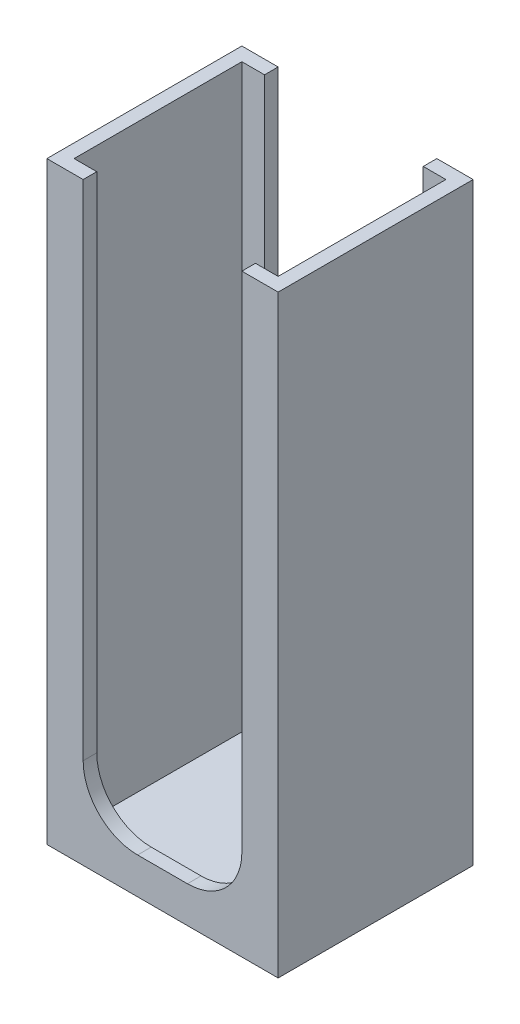
from build123d import *

# Parameters (mm, degrees)
SKETCH1_W           = 25.5
SKETCH1_H           = 21.5
BOSS_EXTRUDE1_DEPTH = 65.5
SKETCH2_W           = 22.5
SKETCH2_H           = 18.5
CUT_EXTRUDE1_DEPTH  = 64
CUT_EXTRUDE2_DEPTH  = 21.5


with BuildPart() as part:
    # Sketch1 → Boss-Extrude1 (new body)
    with BuildSketch(Plane(origin=(0, 0, 0), x_dir=(1, 0, 0), z_dir=(0, 1, 0))):
        with Locations((-53.846079549, -25.043168737)):
            Rectangle(SKETCH1_W, SKETCH1_H)
    extrude(amount=BOSS_EXTRUDE1_DEPTH)

    # Sketch2 → Cut-Extrude1 (cut)
    with BuildSketch(Plane(origin=(0, 65.5, 0), x_dir=(1, 0, 0), z_dir=(0, 1, 0))):
        with Locations((-53.846079549, -25.043168737)):
            Rectangle(SKETCH2_W, SKETCH2_H)
    extrude(amount=-CUT_EXTRUDE1_DEPTH, mode=Mode.SUBTRACT)

    # Sketch5 → Cut-Extrude2 (cut)
    with BuildSketch(Plane.XY.offset(35.793168737)):
        with BuildLine():
            Line((-45.096079549, 65.5), (-62.596079549, 65.5))
            Line((-62.596079549, 65.5), (-62.596079549, 10))
            ThreePointArc((-62.596079549, 10), (-60.838720236, 5.757359313), (-56.596079549, 4))
            Line((-56.596079549, 4), (-51.096079549, 4))
            ThreePointArc((-51.096079549, 4), (-46.853438862, 5.757359313), (-45.096079549, 10))
            Line((-45.096079549, 10), (-45.096079549, 65.5))
        make_face()
    extrude(amount=-CUT_EXTRUDE2_DEPTH, mode=Mode.SUBTRACT)


solid = part.part
